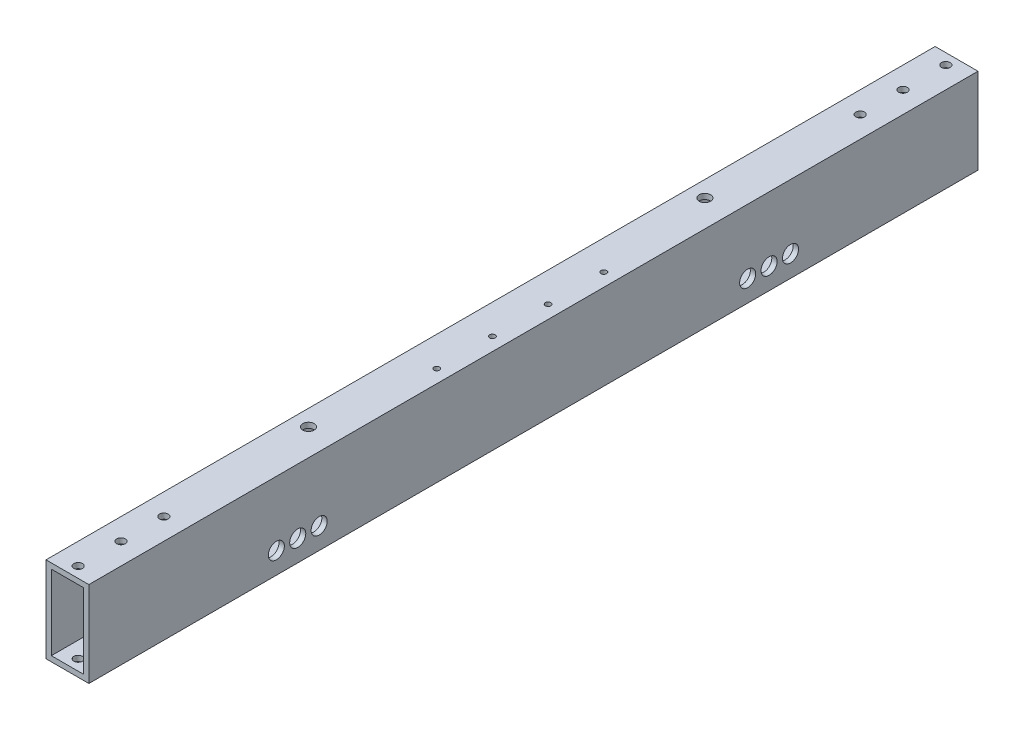
from build123d import *

# Parameters (mm, degrees)
SKETCH1_W                                       = 25.4
SKETCH1_H                                       = 50.8
SKETCH1_W_2                                     = 19.05
SKETCH1_H_2                                     = 44.45
EXTRUDE_THIN1_DEPTH                             = 527.05
F_10_CLEARANCE_HOLE1_D                          = 5.1054
F_1_8_0_13_DIAMETER_HOLE1_D                     = 3.302
F_1_8_0_13_DIAMETER_HOLE1_DEPTH                 = 3.175
F_1_8_0_13_DIAMETER_HOLE2_D                     = 3.302
F_1_8_0_13_DIAMETER_HOLE2_DEPTH                 = 3.175
F_1_4_CLEARANCE_HOLE1_D                         = 6.7564
F_1_4_CLEARANCE_HOLE1_DEPTH                     = 10.7188
F_1_4_CLEARANCE_HOLE1_TIP                       = 2.029827343
CBORE_FOR_10_SOCKET_HEAD_CAP_SCREW1_D           = 5.1054
CBORE_FOR_10_SOCKET_HEAD_CAP_SCREW1_CBORE_D     = 9.525
CBORE_FOR_10_SOCKET_HEAD_CAP_SCREW1_CBORE_DEPTH = 8.001


with BuildPart() as part:
    # Sketch1 → Extrude-Thin1 (new body)
    with BuildSketch(Plane.XY):
        Rectangle(SKETCH1_W, SKETCH1_H)
        Rectangle(SKETCH1_W_2, SKETCH1_H_2, mode=Mode.SUBTRACT)
    extrude(amount=EXTRUDE_THIN1_DEPTH)

    # #10 Clearance Hole1 (through all)
    with Locations(Plane(origin=(0, 25.4, 0), x_dir=(1, 0, 0), z_dir=(0, 1, 0))):
        with Locations((0, -520.7), (0, -495.3), (0, -469.9), (0, -6.35), (0, -31.75), (0, -57.15)):
            Hole(F_10_CLEARANCE_HOLE1_D / 2)

    # 1/8 (0.13) Diameter Hole1
    with Locations(Plane(origin=(0, -25.4, 0), x_dir=(-1, 0, 0), z_dir=(0, -1, 0))):
        with Locations((3.175, -451.358), (-3.175, -425.958), (3.175, -400.558), (-3.175, -375.158), (3.175, -349.758), (3.175, -298.958), (3.175, -248.158), (-3.175, -222.758), (3.175, -197.358), (-3.175, -171.958), (3.175, -146.558), (-3.175, -121.158), (-3.175, -70.358), (-3.175, -324.358), (-3.175, -273.558), (3.175, -95.758)):
            Hole(F_1_8_0_13_DIAMETER_HOLE1_D / 2, depth=F_1_8_0_13_DIAMETER_HOLE1_DEPTH)

    # 1/8 (0.13) Diameter Hole2
    with Locations(Plane(origin=(0, 25.4, 0), x_dir=(1, 0, 0), z_dir=(0, 1, 0))):
        with Locations((4.92125, -313.055), (4.92125, -280.035), (4.92125, -247.015), (4.92125, -213.995)):
            Hole(F_1_8_0_13_DIAMETER_HOLE2_D / 2, depth=F_1_8_0_13_DIAMETER_HOLE2_DEPTH)

    # 1/4 Clearance Hole1
    with Locations(Plane(origin=(0, 25.4, 0), x_dir=(1, 0, 0), z_dir=(0, 1, 0))):
        with Locations((-3.175, -146.05), (-3.175, -381)):
            Hole(F_1_4_CLEARANCE_HOLE1_D / 2, depth=F_1_4_CLEARANCE_HOLE1_DEPTH)
            with Locations((0, 0, -(F_1_4_CLEARANCE_HOLE1_DEPTH + F_1_4_CLEARANCE_HOLE1_TIP / 2))):  # 118° drill point
                Cone(0, F_1_4_CLEARANCE_HOLE1_D / 2, F_1_4_CLEARANCE_HOLE1_TIP, mode=Mode.SUBTRACT)

    # CBORE for #10 Socket Head Cap Screw1 (through all)
    with Locations(Plane(origin=(12.7, 0, 0), x_dir=(0, 0, -1), z_dir=(1, 0, 0))):
        with Locations((-111.125, -12.7), (-123.825, -12.7), (-136.525, -12.7), (-390.525, -12.7), (-415.925, -12.7), (-403.225, -12.7)):
            CounterBoreHole(CBORE_FOR_10_SOCKET_HEAD_CAP_SCREW1_D / 2, CBORE_FOR_10_SOCKET_HEAD_CAP_SCREW1_CBORE_D / 2, CBORE_FOR_10_SOCKET_HEAD_CAP_SCREW1_CBORE_DEPTH)


solid = part.part
